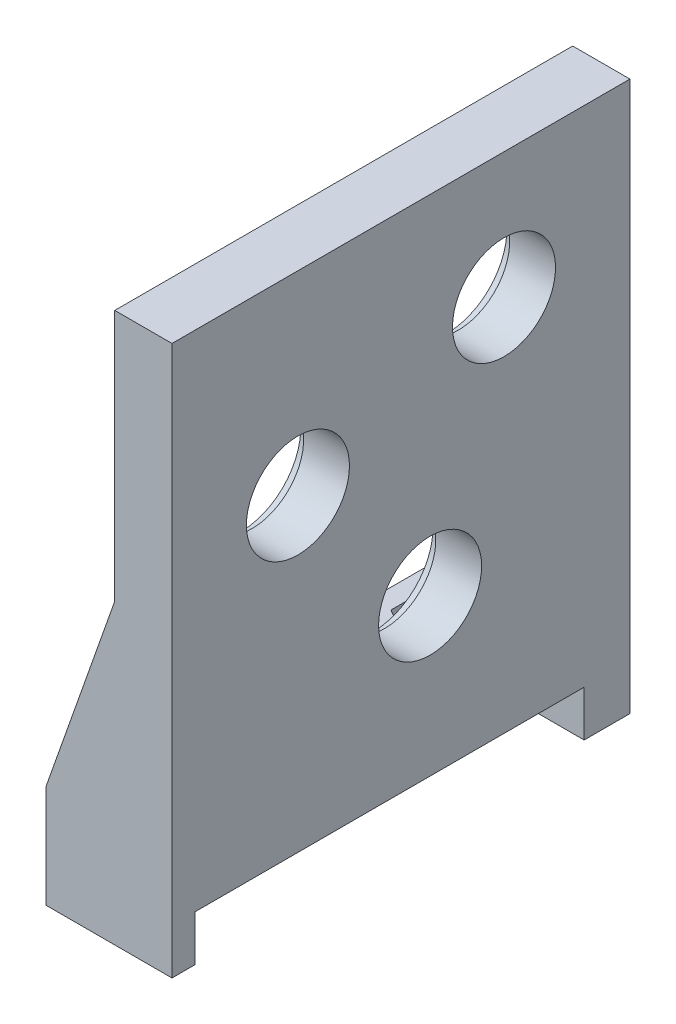
from build123d import *

# Parameters (mm, degrees)
SKETCH_1_W               = 40
SKETCH_1_H               = 44
SKETCH_1_R               = 4.5
EXTRUDE_1_DEPTH          = 5
SKETCH_2_R               = 5.25
CUT_EXTRUDE_1_DEPTH      = 1
SKETCH_3_W               = 40
SKETCH_3_H               = 5
EXTRUDE_2_DEPTH          = 6
EXTRUDE_3_DEPTH          = 4
SKETCH_5_R               = 1.5
CUT_EXTRUDE_2_DEPTH      = 5
CUT_EXTRUDE_3_DEPTH      = 0.5
CUT_EXTRUDE_3_DEPTH_BACK = 2.5
EXTRUDE_4_DEPTH          = 3
EXTRUDE_5_DEPTH          = 3


with BuildPart() as part:
    # 草图1 → 凸台-拉伸1 (new body)
    with BuildSketch(Plane(origin=(0, 0, 0), x_dir=(0, 0, -1), z_dir=(1, 0, 0))):
        with Locations((9, -5)):
            Rectangle(SKETCH_1_W, SKETCH_1_H)
        Circle(SKETCH_1_R, mode=Mode.SUBTRACT)
        with Locations((18, 6)):
            Circle(SKETCH_1_R, mode=Mode.SUBTRACT)
        with Locations((11.543885882, -13.351449313)):
            Circle(SKETCH_1_R, mode=Mode.SUBTRACT)
    extrude(amount=EXTRUDE_1_DEPTH)

    # 草图2 → 切除-拉伸1 (cut)
    with BuildSketch(Plane.ZY):
        with Locations((-18, 6)):
            Circle(SKETCH_2_R)
        Circle(SKETCH_2_R)
        with Locations((-11.543885882, -13.351449313)):
            Circle(SKETCH_2_R)
    extrude(amount=-CUT_EXTRUDE_1_DEPTH, mode=Mode.SUBTRACT)

    # 草图3 → 凸台-拉伸2 (add)
    with BuildSketch(Plane.ZY):
        with Locations((-9, -24.5)):
            Rectangle(SKETCH_3_W, SKETCH_3_H)
    extrude(amount=EXTRUDE_2_DEPTH)

    # 草图4 → 凸台-拉伸3 (add)
    with BuildSketch(Plane.XZ.offset(27)):
        Polygon((5, 11), (-6, 11), (-6, 9), (-3.8, 9), (-0.5, 6), (2.8, 9), (5, 9), align=None)
        with BuildLine():
            Line((5, -29), (-4, -29))
            ThreePointArc((-4, -29), (-6, -27), (-4, -25))
            Line((-4, -25), (5, -25))
            Line((5, -25), (5, -29))
        make_face()
    extrude(amount=EXTRUDE_3_DEPTH)

    # 草图5 → 切除-拉伸2 (cut)
    with BuildSketch(Plane.XZ.offset(27)):
        with Locations((-1.5, -19)):
            Circle(SKETCH_5_R)
        with Locations((-1.5, 1)):
            Circle(SKETCH_5_R)
    extrude(amount=-CUT_EXTRUDE_2_DEPTH, mode=Mode.SUBTRACT)

    # 草图6 → 切除-拉伸3 (cut, two sides)
    with BuildSketch(Plane(origin=(0, -22, 0), x_dir=(1, 0, 0), z_dir=(0, 1, 0))) as cut_extrude_3_sk:
        Polygon((-1.5, 15.795706006), (1.275, 17.397853003), (1.275, 20.602146997), (-1.5, 22.204293994), (-4.275, 20.602146997), (-4.275, 17.397853003), align=None)
        Polygon((-4.704293994, -1), (-3.102146997, -3.775), (0.102146997, -3.775), (1.704293994, -1), (0.102146997, 1.775), (-3.102146997, 1.775), align=None)
    extrude(amount=CUT_EXTRUDE_3_DEPTH, mode=Mode.SUBTRACT)
    extrude(cut_extrude_3_sk.sketch, amount=-CUT_EXTRUDE_3_DEPTH_BACK, mode=Mode.SUBTRACT)

    # 草图7 → 凸台-拉伸4 (add)
    with BuildSketch(Plane.XY.offset(11)):
        Polygon((0, -22), (-6, -22), (0, -5), align=None)
    extrude(amount=-EXTRUDE_4_DEPTH)

    # 草图8 → 凸台-拉伸5 (add)
    with BuildSketch(Plane(origin=(0, 0, -29), x_dir=(-1, 0, 0), z_dir=(0, 0, -1))):
        Polygon((0, -22), (6, -22), (0, -5), align=None)
    extrude(amount=-EXTRUDE_5_DEPTH)


solid = part.part
